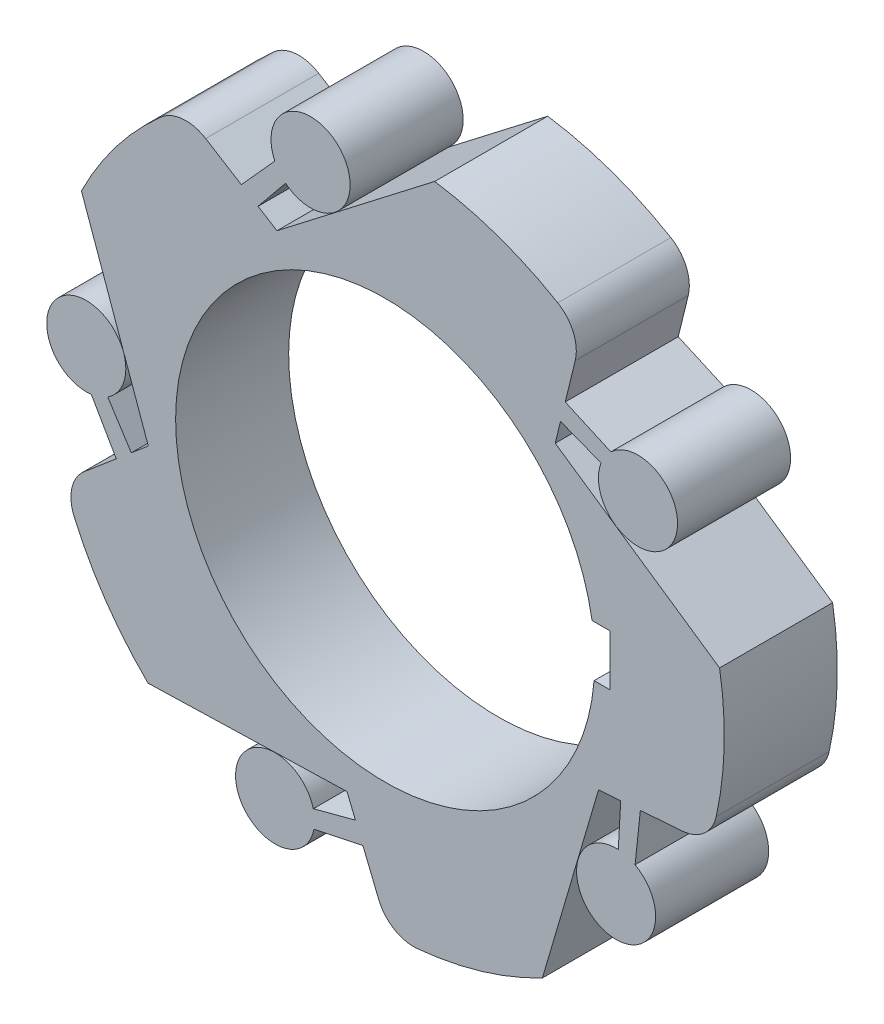
from build123d import *

# Parameters (mm, degrees)
SKETCH1_R             = 90
BOSS_EXTRUDE1_DEPTH   = 30
CUT_EXTRUDE4_DEPTH    = 30
SKETCH5_R             = 55.626023842
CUT_EXTRUDE5_DEPTH    = 30
SKETCH6_W             = 7.386739777
SKETCH6_H             = 13.542356258
CUT_EXTRUDE6_DEPTH    = 30
FILLET1_R             = 10
SKETCH8_R             = 10.49811893
BOSS_EXTRUDE2_DEPTH   = 30
BOSS_EXTRUDE2_2_DEPTH = 30
BOSS_EXTRUDE2_3_DEPTH = 30
BOSS_EXTRUDE2_4_DEPTH = 30
BOSS_EXTRUDE2_5_DEPTH = 30
BOSS_EXTRUDE4_DEPTH   = 30


with BuildPart() as part:
    # Sketch1 → Boss-Extrude1 (new body)
    with BuildSketch(Plane.XY):
        Circle(SKETCH1_R)
    extrude(amount=BOSS_EXTRUDE1_DEPTH)

    # Sketch4 → Cut-Extrude4 (cut)
    with BuildSketch(Plane.XY):
        with BuildLine():
            Line((88.736574157, 15.027322012), (45.122701232, 44.870398789))
            Line((45.122701232, 44.870398789), (52.120312028, 73.372154623))
            ThreePointArc((52.120312028, 73.372154623), (76.231197482, 47.84145201), (88.736574157, 15.027322012))
        make_face()
        with BuildLine():
            Line((41.712941959, -79.749799204), (56.61796667, -29.048523269))
            Line((56.61796667, -29.048523269), (85.887127938, -26.896119693))
            ThreePointArc((85.887127938, -26.896119693), (69.056660207, -57.716355404), (41.712941959, -79.749799204))
        make_face()
        with BuildLine():
            Line((-62.956558256, -64.315408516), (-10.130873456, -62.823373493))
            Line((-10.130873456, -62.823373493), (0.960852233, -89.994870759))
            ThreePointArc((0.960852233, -89.994870759), (-33.551834325, -83.512121356), (-62.956558256, -64.315408516))
        make_face()
        with BuildLine():
            Line((-80.622234776, 40.000690741), (-62.879190802, -9.778456837))
            Line((-62.879190802, -9.778456837), (-85.2932886, -28.723769249))
            ThreePointArc((-85.2932886, -28.723769249), (-89.792834204, 6.103025933), (-80.622234776, 40.000690741))
        make_face()
        with BuildLine():
            Line((13.129276916, 89.037194967), (-28.730603645, 56.77995481))
            Line((-28.730603645, 56.77995481), (-53.6750036, 72.242605078))
            ThreePointArc((-53.6750036, 72.242605078), (-21.943189159, 87.283998817), (13.129276916, 89.037194967))
        make_face()
    extrude(amount=CUT_EXTRUDE4_DEPTH, mode=Mode.SUBTRACT)

    # Sketch5 → Cut-Extrude5 (cut)
    with BuildSketch(Plane.XY):
        Circle(SKETCH5_R)
    extrude(amount=CUT_EXTRUDE5_DEPTH, mode=Mode.SUBTRACT)

    # Sketch6 → Cut-Extrude6 (cut)
    with BuildSketch(Plane.XY):
        with Locations((56.030331415, 2.229633356)):
            Rectangle(SKETCH6_W, SKETCH6_H)
    extrude(amount=CUT_EXTRUDE6_DEPTH, mode=Mode.SUBTRACT)

    # Fillet1
    fillet1_edges = [part.edges().sort_by_distance(p)[0] for p in [
        (85.887127938, -26.896119693, 15),
        (0.960852233, -89.994870759, 15),
        (-85.2932886, -28.723769249, 15),
        (-53.6750036, 72.242605078, 15),
        (52.120312028, 73.372154623, 15),
    ]]
    fillet(fillet1_edges, radius=FILLET1_R)



with BuildPart() as body_2:
    # Sketch8 → Boss-Extrude2 (new body)
    with BuildSketch(Plane.XY.offset(30)):
        with Locations((67.093562258, 42.627771692)):
            Circle(SKETCH8_R)
    extrude(amount=-BOSS_EXTRUDE2_DEPTH)


with BuildPart() as body_3:
    # Sketch8 → Boss-Extrude2 2 (new body)
    with BuildSketch(Plane.XY.offset(30)):
        with Locations((61.274470993, -50.637063702)):
            Circle(SKETCH8_R)
    extrude(amount=-BOSS_EXTRUDE2_2_DEPTH)


with BuildPart() as body_4:
    # Sketch8 → Boss-Extrude2 3 (new body)
    with BuildSketch(Plane.XY.offset(30)):
        with Locations((-29.223856541, -73.92319815)):
            Circle(SKETCH8_R)
    extrude(amount=-BOSS_EXTRUDE2_3_DEPTH)


with BuildPart() as body_5:
    # Sketch8 → Boss-Extrude2 4 (new body)
    with BuildSketch(Plane.XY.offset(30)):
        with Locations((-79.335807618, 4.950014688)):
            Circle(SKETCH8_R)
    extrude(amount=-BOSS_EXTRUDE2_4_DEPTH)


with BuildPart() as body_6:
    # Sketch8 → Boss-Extrude2 5 (new body)
    with BuildSketch(Plane.XY.offset(30)):
        with Locations((-19.808369092, 76.982475472)):
            Circle(SKETCH8_R)
    extrude(amount=-BOSS_EXTRUDE2_5_DEPTH)


with BuildPart() as part_1:
    add(part.part)

    add(body_2.part)  # Boss-Extrude4 merges body 2

    add(body_3.part)  # Boss-Extrude4 merges body 3

    add(body_4.part)  # Boss-Extrude4 merges body 4

    add(body_5.part)  # Boss-Extrude4 merges body 5

    add(body_6.part)  # Boss-Extrude4 merges body 6
    # Sketch9 → Boss-Extrude4 (add)
    with BuildSketch(Plane.XY):
        with BuildLine():
            Line((-29.298411126, 72.493644527), (-38.186452488, 62.641490221))
            Line((-38.186452488, 62.641490221), (-33.742460025, 59.886727574))
            Line((-33.742460025, 59.886727574), (-26.440954647, 68.84495067))
            ThreePointArc((-26.440954647, 68.84495067), (-28.073538286, 70.509649254), (-29.298411126, 72.493644527))
        make_face()
        with BuildLine():
            Line((46.528668919, 50.597003041), (57.304734615, 46.421101948))
            ThreePointArc((57.304734615, 46.421101948), (58.383460962, 48.48820141), (59.891846071, 50.266212961))
            Line((59.891846071, 50.266212961), (47.775334692, 55.674759504))
            Line((47.775334692, 55.674759504), (46.528668919, 50.597003041))
        make_face()
        with BuildLine():
            Line((62.498758869, -28.616059966), (61.857228356, -40.15513187))
            ThreePointArc((61.857228356, -40.15513187), (64.156501542, -40.54229273), (66.313607647, -41.427416431))
            Line((66.313607647, -41.427416431), (67.713233152, -28.232596532))
            Line((67.713233152, -28.232596532), (62.498758869, -28.616059966))
        make_face()
        with BuildLine():
            Line((-7.902311684, -68.282700724), (-19.074865041, -71.238338267))
            ThreePointArc((-19.074865041, -71.238338267), (-18.73256241, -73.544716298), (-18.907782629, -75.869764382))
            Line((-18.907782629, -75.869764382), (-5.926255116, -73.123463752))
            Line((-5.926255116, -73.123463752), (-7.902311684, -68.282700724))
        make_face()
        with BuildLine():
            Line((-67.382656079, -13.584969925), (-73.646143282, -3.872582481))
            ThreePointArc((-73.646143282, -3.872582481), (-75.733861807, -4.910841636), (-77.999259963, -5.462676675))
            Line((-77.999259963, -5.462676675), (-71.375860239, -16.960189442))
            Line((-71.375860239, -16.960189442), (-67.382656079, -13.584969925))
        make_face()
    extrude(amount=BOSS_EXTRUDE4_DEPTH)


solid = part_1.part
